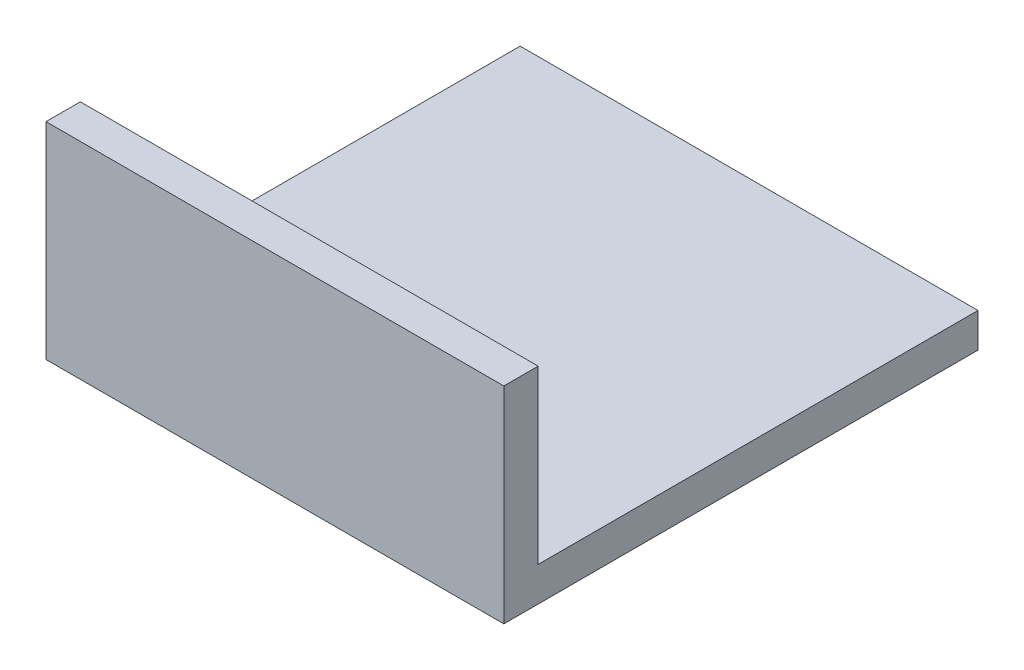
from build123d import *

# Parameters (mm, degrees)
SKETCH1_W           = 127
SKETCH1_H           = 57.15
BOSS_EXTRUDE1_DEPTH = 9.525
SKETCH2_W           = 127
SKETCH2_H           = 127
BOSS_EXTRUDE3_DEPTH = 9.525
SKETCH3_R           = 10.16
CUT_EXTRUDE1_DEPTH  = 5.0038


with BuildPart() as part:
    # Sketch1 → Boss-Extrude1 (new body)
    with BuildSketch(Plane.XY):
        with Locations((63.5, 28.575)):
            Rectangle(SKETCH1_W, SKETCH1_H)
    extrude(amount=BOSS_EXTRUDE1_DEPTH)

    # Sketch2 → Boss-Extrude3 (add)
    with BuildSketch(Plane(origin=(0, 0, 0), x_dir=(1, 0, 0), z_dir=(0, 1, 0))):
        with Locations((63.5, 58.4962)):
            Rectangle(SKETCH2_W, SKETCH2_H)
    extrude(amount=BOSS_EXTRUDE3_DEPTH)

    # Sketch3 → Cut-Extrude1 (cut)
    with BuildSketch(Plane(origin=(0, 0, 0), x_dir=(1, 0, 0), z_dir=(0, 1, 0))):
        with Locations((63.5, 36.322)):
            Circle(SKETCH3_R)
    extrude(amount=CUT_EXTRUDE1_DEPTH, mode=Mode.SUBTRACT)


solid = part.part
